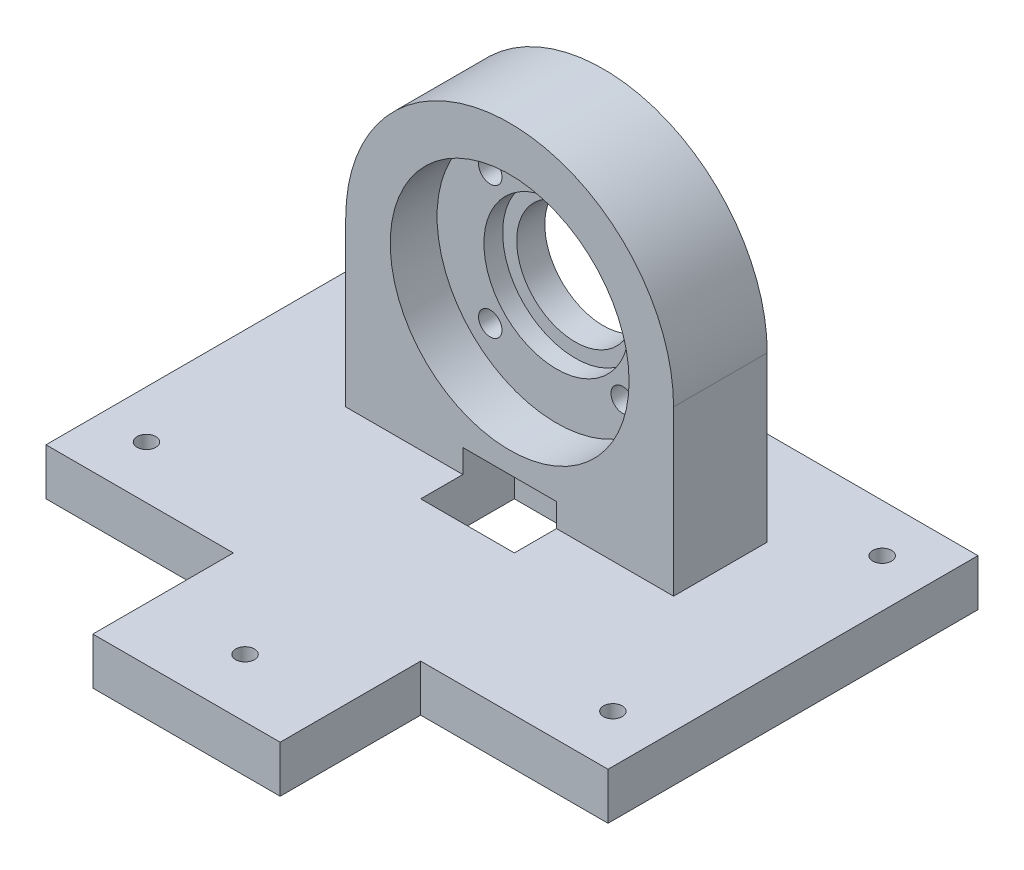
from build123d import *

# Parameters (mm, degrees)
SKETCH1_R           = 2
BOSS_EXTRUDE1_DEPTH = 10
SKETCH2_W           = 70
SKETCH2_H           = 20
BOSS_EXTRUDE2_DEPTH = 70
CUT_EXTRUDE1_DEPTH  = 20
SKETCH4_R           = 25.5
CUT_EXTRUDE2_DEPTH  = 10
SKETCH5_R           = 15.5
CUT_EXTRUDE3_DEPTH  = 4
SKETCH6_R           = 2.5
CUT_EXTRUDE4_DEPTH  = 10
SKETCH7_R           = 12.5
CUT_EXTRUDE5_DEPTH  = 6
SKETCH8_W           = 20
SKETCH8_H           = 20
CUT_EXTRUDE6_DEPTH  = 15


with BuildPart() as part:
    # Sketch1 → Boss-Extrude1 (new body)
    with BuildSketch(Plane(origin=(0, 0, 0), x_dir=(1, 0, 0), z_dir=(0, 1, 0))):
        Polygon((-35, -40), (-20, -40), (-20, -70), (20, -70), (20, -40), (35, -40), (60, -40), (60, 39), (-60, 39), (-60, -40), align=None)
        with Locations((49.796460718, 28.75)):
            Circle(SKETCH1_R, mode=Mode.SUBTRACT)
        with Locations((49.796460718, -28.75)):
            Circle(SKETCH1_R, mode=Mode.SUBTRACT)
        with Locations((0, -57.5)):
            Circle(SKETCH1_R, mode=Mode.SUBTRACT)
        with Locations((-49.796460718, -28.75)):
            Circle(SKETCH1_R, mode=Mode.SUBTRACT)
        with Locations((-49.796460718, 28.75)):
            Circle(SKETCH1_R, mode=Mode.SUBTRACT)
    extrude(amount=BOSS_EXTRUDE1_DEPTH)

    # Sketch2 → Boss-Extrude2 (add)
    with BuildSketch(Plane(origin=(0, 10, 0), x_dir=(1, 0, 0), z_dir=(0, 1, 0))):
        with Locations((0, 9)):
            Rectangle(SKETCH2_W, SKETCH2_H)
    extrude(amount=BOSS_EXTRUDE2_DEPTH)

    # Sketch3 → Cut-Extrude1 (cut)
    with BuildSketch(Plane(origin=(0, 0, -19), x_dir=(-1, 0, 0), z_dir=(0, 0, -1))):
        with BuildLine():
            ThreePointArc((-35, 45), (-24.748737331, 69.748737352), (3e-08, 80))
            Line((3e-08, 80), (-35, 80))
            Line((-35, 80), (-35, 45))
        make_face()
        with BuildLine():
            Line((35, 45), (35, 80))
            Line((35, 80), (3e-08, 80))
            ThreePointArc((3e-08, 80), (24.748737352, 69.748737331), (35, 45))
        make_face()
    extrude(amount=-CUT_EXTRUDE1_DEPTH, mode=Mode.SUBTRACT)

    # Sketch4 → Cut-Extrude2 (cut)
    with BuildSketch(Plane.XY.offset(1)):
        with Locations((0, 45)):
            Circle(SKETCH4_R)
    extrude(amount=-CUT_EXTRUDE2_DEPTH, mode=Mode.SUBTRACT)

    # Sketch5 → Cut-Extrude3 (cut)
    with BuildSketch(Plane.XY.offset(-9)):
        with Locations((0, 45)):
            Circle(SKETCH5_R)
    extrude(amount=-CUT_EXTRUDE3_DEPTH, mode=Mode.SUBTRACT)

    # Sketch6 → Cut-Extrude4 (cut)
    with BuildSketch(Plane.XY.offset(-9)):
        with Locations((14.142135624, 59.142135624)):
            Circle(SKETCH6_R)
        with Locations((14.142135624, 30.857864376)):
            Circle(SKETCH6_R)
        with Locations((-14.142135624, 30.857864376)):
            Circle(SKETCH6_R)
        with Locations((-14.142135624, 59.142135624)):
            Circle(SKETCH6_R)
    extrude(amount=-CUT_EXTRUDE4_DEPTH, mode=Mode.SUBTRACT)

    # Sketch7 → Cut-Extrude5 (cut)
    with BuildSketch(Plane.XY.offset(-13)):
        with Locations((0, 45)):
            Circle(SKETCH7_R)
    extrude(amount=-CUT_EXTRUDE5_DEPTH, mode=Mode.SUBTRACT)

    # Sketch8 → Cut-Extrude6 (cut)
    with BuildSketch(Plane.XZ):
        Rectangle(SKETCH8_W, SKETCH8_H)
    extrude(amount=-CUT_EXTRUDE6_DEPTH, mode=Mode.SUBTRACT)


solid = part.part
